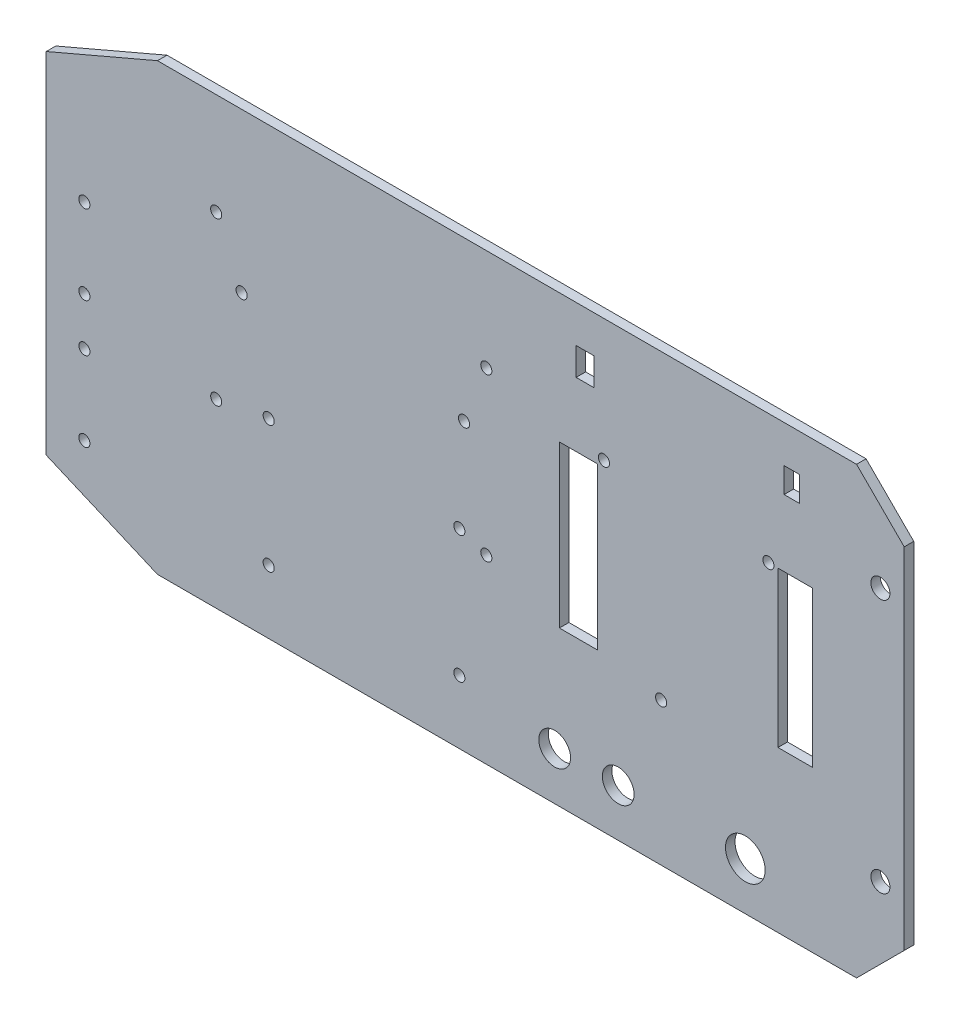
from build123d import *

# Parameters (mm, degrees)
SKETCH1_W           = 270
SKETCH1_H           = 140
BOSS_EXTRUDE1_DEPTH = 3
SKETCH2_R           = 6.25
SKETCH2_R_2         = 5
CUT_EXTRUDE1_DEPTH  = 3
CUT_EXTRUDE3_DEPTH  = 3
SKETCH6_W           = 12.019056062
SKETCH6_H           = 50.71745121
SKETCH6_W_2         = 10.934400461
SKETCH6_H_2         = 48.883202059
SKETCH6_W_3         = 5.676391459
SKETCH6_H_3         = 8.689402458
SKETCH6_W_4         = 4.853726277
SKETCH6_H_4         = 7.896916359
CUT_EXTRUDE5_DEPTH  = 10
SKETCH7_R           = 1.75
CUT_EXTRUDE8_DEPTH  = 10
SKETCH8_R           = 1.75
CUT_EXTRUDE9_DEPTH  = 10
SKETCH9_R           = 1.75
SKETCH9_R_2         = 3
CUT_EXTRUDE10_DEPTH = 10
SKETCH10_R          = 1.75
CUT_EXTRUDE11_DEPTH = 10


with BuildPart() as part:
    # Sketch1 → Boss-Extrude1 (new body)
    with BuildSketch(Plane.XY):
        with Locations((135, 70)):
            Rectangle(SKETCH1_W, SKETCH1_H)
    extrude(amount=BOSS_EXTRUDE1_DEPTH)

    # Sketch2 → Cut-Extrude1 (cut)
    with BuildSketch(Plane.XY.offset(3)):
        with Locations((220, 15)):
            Circle(SKETCH2_R)
        with Locations((180, 15)):
            Circle(SKETCH2_R_2)
        with Locations((160, 15)):
            Circle(SKETCH2_R_2)
    extrude(amount=-CUT_EXTRUDE1_DEPTH, mode=Mode.SUBTRACT)

    # Sketch5 → Cut-Extrude3 (cut)
    with BuildSketch(Plane.XY.offset(3)):
        Polygon((255, 140), (270, 125), (270, 140), align=None)
        Polygon((0, 140), (0, 125), (35, 140), align=None)
        Polygon((270, 0), (255, 0), (270, 15), align=None)
        Polygon((0, 15), (35, 0), (0, 0), align=None)
    extrude(amount=-CUT_EXTRUDE3_DEPTH, mode=Mode.SUBTRACT)

    # Sketch6 → Cut-Extrude5 (cut)
    with BuildSketch(Plane(origin=(0, 0, 0), x_dir=(-1, 0, 0), z_dir=(0, 0, -1))):
        with Locations((-167.493263023, 73.985112913)):
            Rectangle(SKETCH6_W, SKETCH6_H)
        with Locations((-235.732393676, 74.902237489)):
            Rectangle(SKETCH6_W_2, SKETCH6_H_2)
        with Locations((-169.594169913, 123.903401406)):
            Rectangle(SKETCH6_W_3, SKETCH6_H_3)
        with Locations((-234.619547555, 124.299644456)):
            Rectangle(SKETCH6_W_4, SKETCH6_H_4)
    extrude(amount=-CUT_EXTRUDE5_DEPTH, mode=Mode.SUBTRACT)

    # Sketch7 → Cut-Extrude8 (cut)
    with BuildSketch(Plane(origin=(0, 0, 0), x_dir=(-1, 0, 0), z_dir=(0, 0, -1))):
        with Locations((-53.483734992, 57)):
            Circle(SKETCH7_R)
        with Locations((-138.483734992, 57)):
            Circle(SKETCH7_R)
        with Locations((-138.483734992, 108)):
            Circle(SKETCH7_R)
        with Locations((-53.483734992, 108)):
            Circle(SKETCH7_R)
    extrude(amount=-CUT_EXTRUDE8_DEPTH, mode=Mode.SUBTRACT)

    # Sketch8 → Cut-Extrude9 (cut)
    with BuildSketch(Plane(origin=(0, 0, 0), x_dir=(-1, 0, 0), z_dir=(0, 0, -1))):
        with Locations((-12, 25)):
            Circle(SKETCH8_R)
        with Locations((-12, 65)):
            Circle(SKETCH8_R)
        with Locations((-12, 50)):
            Circle(SKETCH8_R)
        with Locations((-12, 90)):
            Circle(SKETCH8_R)
    extrude(amount=-CUT_EXTRUDE9_DEPTH, mode=Mode.SUBTRACT)

    # Sketch9 → Cut-Extrude10 (cut)
    with BuildSketch(Plane(origin=(0, 0, 0), x_dir=(-1, 0, 0), z_dir=(0, 0, -1))):
        with Locations((-70, 20)):
            Circle(SKETCH9_R)
        with Locations((-130, 20)):
            Circle(SKETCH9_R)
        with Locations((-130, 60)):
            Circle(SKETCH9_R)
        with Locations((-70, 60)):
            Circle(SKETCH9_R)
        with Locations((-61.483734992, 90)):
            Circle(SKETCH9_R)
        with Locations((-131.483734992, 90)):
            Circle(SKETCH9_R)
        with Locations((-262.5, 30)):
            Circle(SKETCH9_R_2)
        with Locations((-262.5, 110)):
            Circle(SKETCH9_R_2)
    extrude(amount=-CUT_EXTRUDE10_DEPTH, mode=Mode.SUBTRACT)

    # Sketch10 → Cut-Extrude11 (cut)
    with BuildSketch(Plane(origin=(0, 0, 0), x_dir=(-1, 0, 0), z_dir=(0, 0, -1))):
        with Locations((-193.502791054, 45)):
            Circle(SKETCH10_R)
        with Locations((-175.502791054, 101.343838518)):
            Circle(SKETCH10_R)
        with Locations((-227.265193445, 99.343838518)):
            Circle(SKETCH10_R)
    extrude(amount=-CUT_EXTRUDE11_DEPTH, mode=Mode.SUBTRACT)


solid = part.part
